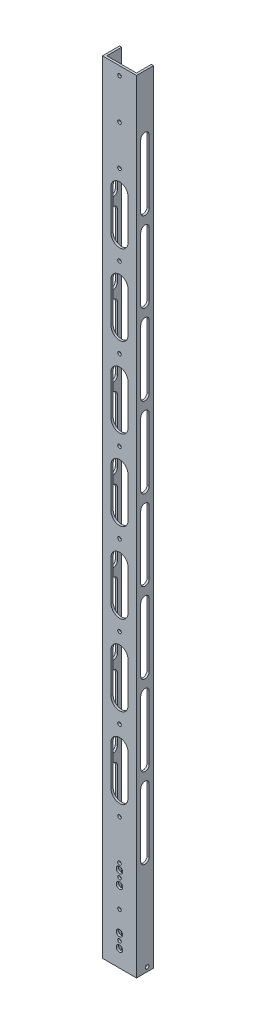
from build123d import *

# Parameters (mm, degrees)
BOSS_EXTRUDE1_DEPTH = 1168.4
IGUS_HOLES_REACH    = 27.4
SKETCH2_R           = 2.667
CUT_EXTRUDE2_REACH  = 5.175
SKETCH3_R           = 4.7625
SKETCH3_R_2         = 2.667
SKETCH4_R           = 2.667
CUT_EXTRUDE3_DEPTH  = 51.8
BACK_CUTS_REACH     = 27.4
CUT_EXTRUDE5_DEPTH  = 51.8


with BuildPart() as part:
    # Sketch1 → Boss-Extrude1 (new body)
    with BuildSketch(Plane(origin=(0, 0, 0), x_dir=(1, 0, 0), z_dir=(0, 1, 0))):
        Polygon((3.175, 3.175), (3.175, 25.4), (0, 25.4), (0, 0), (50.8, 0), (50.8, 25.4), (47.625, 25.4), (47.625, 3.175), align=None)
    extrude(amount=BOSS_EXTRUDE1_DEPTH)

    # Sketch2 → Igus_Holes (cut, up to next)
    with BuildSketch(Plane.XY, mode=Mode.PRIVATE) as igus_holes_sk1:
        with Locations((25.4, 76.2)):
            Circle(SKETCH2_R)
    igus_holes_tool1 = extrude(igus_holes_sk1.sketch, amount=-IGUS_HOLES_REACH, mode=Mode.PRIVATE) & part.part
    add(igus_holes_tool1.solids().sort_by_distance((25.4, 76.2, 0))[0], mode=Mode.SUBTRACT)
    # Sketch2 → Igus_Holes (cut, up to next)
    with BuildSketch(Plane.XY, mode=Mode.PRIVATE) as igus_holes_sk2:
        with Locations((25.4, 136.144)):
            Circle(SKETCH2_R)
    igus_holes_tool2 = extrude(igus_holes_sk2.sketch, amount=-IGUS_HOLES_REACH, mode=Mode.PRIVATE) & part.part
    add(igus_holes_tool2.solids().sort_by_distance((25.4, 136.144, 0))[0], mode=Mode.SUBTRACT)
    # Sketch2 → Igus_Holes (cut, up to next)
    with BuildSketch(Plane.XY, mode=Mode.PRIVATE) as igus_holes_sk3:
        with Locations((25.4, 196.088)):
            Circle(SKETCH2_R)
    igus_holes_tool3 = extrude(igus_holes_sk3.sketch, amount=-IGUS_HOLES_REACH, mode=Mode.PRIVATE) & part.part
    add(igus_holes_tool3.solids().sort_by_distance((25.4, 196.088, 0))[0], mode=Mode.SUBTRACT)
    # Sketch2 → Igus_Holes (cut, up to next)
    with BuildSketch(Plane.XY, mode=Mode.PRIVATE) as igus_holes_sk4:
        with Locations((25.4, 256.032)):
            Circle(SKETCH2_R)
    igus_holes_tool4 = extrude(igus_holes_sk4.sketch, amount=-IGUS_HOLES_REACH, mode=Mode.PRIVATE) & part.part
    add(igus_holes_tool4.solids().sort_by_distance((25.4, 256.032, 0))[0], mode=Mode.SUBTRACT)
    # Sketch2 → Igus_Holes (cut, up to next)
    with BuildSketch(Plane.XY, mode=Mode.PRIVATE) as igus_holes_sk5:
        with Locations((25.4, 315.976)):
            Circle(SKETCH2_R)
    igus_holes_tool5 = extrude(igus_holes_sk5.sketch, amount=-IGUS_HOLES_REACH, mode=Mode.PRIVATE) & part.part
    add(igus_holes_tool5.solids().sort_by_distance((25.4, 315.976, 0))[0], mode=Mode.SUBTRACT)
    # Sketch2 → Igus_Holes (cut, up to next)
    with BuildSketch(Plane.XY, mode=Mode.PRIVATE) as igus_holes_sk6:
        with Locations((25.4, 375.92)):
            Circle(SKETCH2_R)
    igus_holes_tool6 = extrude(igus_holes_sk6.sketch, amount=-IGUS_HOLES_REACH, mode=Mode.PRIVATE) & part.part
    add(igus_holes_tool6.solids().sort_by_distance((25.4, 375.92, 0))[0], mode=Mode.SUBTRACT)
    # Sketch2 → Igus_Holes (cut, up to next)
    with BuildSketch(Plane.XY, mode=Mode.PRIVATE) as igus_holes_sk7:
        with Locations((25.4, 435.864)):
            Circle(SKETCH2_R)
    igus_holes_tool7 = extrude(igus_holes_sk7.sketch, amount=-IGUS_HOLES_REACH, mode=Mode.PRIVATE) & part.part
    add(igus_holes_tool7.solids().sort_by_distance((25.4, 435.864, 0))[0], mode=Mode.SUBTRACT)
    # Sketch2 → Igus_Holes (cut, up to next)
    with BuildSketch(Plane.XY, mode=Mode.PRIVATE) as igus_holes_sk8:
        with Locations((25.4, 495.808)):
            Circle(SKETCH2_R)
    igus_holes_tool8 = extrude(igus_holes_sk8.sketch, amount=-IGUS_HOLES_REACH, mode=Mode.PRIVATE) & part.part
    add(igus_holes_tool8.solids().sort_by_distance((25.4, 495.808, 0))[0], mode=Mode.SUBTRACT)
    # Sketch2 → Igus_Holes (cut, up to next)
    with BuildSketch(Plane.XY, mode=Mode.PRIVATE) as igus_holes_sk9:
        with Locations((25.4, 555.752)):
            Circle(SKETCH2_R)
    igus_holes_tool9 = extrude(igus_holes_sk9.sketch, amount=-IGUS_HOLES_REACH, mode=Mode.PRIVATE) & part.part
    add(igus_holes_tool9.solids().sort_by_distance((25.4, 555.752, 0))[0], mode=Mode.SUBTRACT)
    # Sketch2 → Igus_Holes (cut, up to next)
    with BuildSketch(Plane.XY, mode=Mode.PRIVATE) as igus_holes_sk10:
        with Locations((25.4, 615.696)):
            Circle(SKETCH2_R)
    igus_holes_tool10 = extrude(igus_holes_sk10.sketch, amount=-IGUS_HOLES_REACH, mode=Mode.PRIVATE) & part.part
    add(igus_holes_tool10.solids().sort_by_distance((25.4, 615.696, 0))[0], mode=Mode.SUBTRACT)
    # Sketch2 → Igus_Holes (cut, up to next)
    with BuildSketch(Plane.XY, mode=Mode.PRIVATE) as igus_holes_sk11:
        with Locations((25.4, 675.64)):
            Circle(SKETCH2_R)
    igus_holes_tool11 = extrude(igus_holes_sk11.sketch, amount=-IGUS_HOLES_REACH, mode=Mode.PRIVATE) & part.part
    add(igus_holes_tool11.solids().sort_by_distance((25.4, 675.64, 0))[0], mode=Mode.SUBTRACT)
    # Sketch2 → Igus_Holes (cut, up to next)
    with BuildSketch(Plane.XY, mode=Mode.PRIVATE) as igus_holes_sk12:
        with Locations((25.4, 735.584)):
            Circle(SKETCH2_R)
    igus_holes_tool12 = extrude(igus_holes_sk12.sketch, amount=-IGUS_HOLES_REACH, mode=Mode.PRIVATE) & part.part
    add(igus_holes_tool12.solids().sort_by_distance((25.4, 735.584, 0))[0], mode=Mode.SUBTRACT)
    # Sketch2 → Igus_Holes (cut, up to next)
    with BuildSketch(Plane.XY, mode=Mode.PRIVATE) as igus_holes_sk13:
        with Locations((25.4, 795.528)):
            Circle(SKETCH2_R)
    igus_holes_tool13 = extrude(igus_holes_sk13.sketch, amount=-IGUS_HOLES_REACH, mode=Mode.PRIVATE) & part.part
    add(igus_holes_tool13.solids().sort_by_distance((25.4, 795.528, 0))[0], mode=Mode.SUBTRACT)
    # Sketch2 → Igus_Holes (cut, up to next)
    with BuildSketch(Plane.XY, mode=Mode.PRIVATE) as igus_holes_sk14:
        with Locations((25.4, 855.472)):
            Circle(SKETCH2_R)
    igus_holes_tool14 = extrude(igus_holes_sk14.sketch, amount=-IGUS_HOLES_REACH, mode=Mode.PRIVATE) & part.part
    add(igus_holes_tool14.solids().sort_by_distance((25.4, 855.472, 0))[0], mode=Mode.SUBTRACT)
    # Sketch2 → Igus_Holes (cut, up to next)
    with BuildSketch(Plane.XY, mode=Mode.PRIVATE) as igus_holes_sk15:
        with Locations((25.4, 915.416)):
            Circle(SKETCH2_R)
    igus_holes_tool15 = extrude(igus_holes_sk15.sketch, amount=-IGUS_HOLES_REACH, mode=Mode.PRIVATE) & part.part
    add(igus_holes_tool15.solids().sort_by_distance((25.4, 915.416, 0))[0], mode=Mode.SUBTRACT)
    # Sketch2 → Igus_Holes (cut, up to next)
    with BuildSketch(Plane.XY, mode=Mode.PRIVATE) as igus_holes_sk16:
        with Locations((25.4, 975.36)):
            Circle(SKETCH2_R)
    igus_holes_tool16 = extrude(igus_holes_sk16.sketch, amount=-IGUS_HOLES_REACH, mode=Mode.PRIVATE) & part.part
    add(igus_holes_tool16.solids().sort_by_distance((25.4, 975.36, 0))[0], mode=Mode.SUBTRACT)
    # Sketch2 → Igus_Holes (cut, up to next)
    with BuildSketch(Plane.XY, mode=Mode.PRIVATE) as igus_holes_sk17:
        with Locations((25.4, 1035.304)):
            Circle(SKETCH2_R)
    igus_holes_tool17 = extrude(igus_holes_sk17.sketch, amount=-IGUS_HOLES_REACH, mode=Mode.PRIVATE) & part.part
    add(igus_holes_tool17.solids().sort_by_distance((25.4, 1035.304, 0))[0], mode=Mode.SUBTRACT)
    # Sketch2 → Igus_Holes (cut, up to next)
    with BuildSketch(Plane.XY, mode=Mode.PRIVATE) as igus_holes_sk18:
        with Locations((25.4, 1095.248)):
            Circle(SKETCH2_R)
    igus_holes_tool18 = extrude(igus_holes_sk18.sketch, amount=-IGUS_HOLES_REACH, mode=Mode.PRIVATE) & part.part
    add(igus_holes_tool18.solids().sort_by_distance((25.4, 1095.248, 0))[0], mode=Mode.SUBTRACT)
    # Sketch2 → Igus_Holes (cut, up to next)
    with BuildSketch(Plane.XY, mode=Mode.PRIVATE) as igus_holes_sk19:
        with Locations((25.4, 1155.192)):
            Circle(SKETCH2_R)
    igus_holes_tool19 = extrude(igus_holes_sk19.sketch, amount=-IGUS_HOLES_REACH, mode=Mode.PRIVATE) & part.part
    add(igus_holes_tool19.solids().sort_by_distance((25.4, 1155.192, 0))[0], mode=Mode.SUBTRACT)

    # Sketch3 → Cut-Extrude2 (cut, up to next)
    with BuildSketch(Plane(origin=(0, 0, -3.175), x_dir=(-1, 0, 0), z_dir=(0, 0, -1)), mode=Mode.PRIVATE) as cut_extrude2_sk1:
        with Locations((-25.4, 25.4)):
            Circle(SKETCH3_R)
    cut_extrude2_tool1 = extrude(cut_extrude2_sk1.sketch, amount=-CUT_EXTRUDE2_REACH, mode=Mode.PRIVATE) & part.part
    add(cut_extrude2_tool1.solids().sort_by_distance((25.4, 25.4, -3.175))[0], mode=Mode.SUBTRACT)
    # Sketch3 → Cut-Extrude2 (cut, up to next)
    with BuildSketch(Plane(origin=(0, 0, -3.175), x_dir=(-1, 0, 0), z_dir=(0, 0, -1)), mode=Mode.PRIVATE) as cut_extrude2_sk2:
        with Locations((-25.400000019, 35.39998)):
            Circle(SKETCH3_R_2)
    cut_extrude2_tool2 = extrude(cut_extrude2_sk2.sketch, amount=-CUT_EXTRUDE2_REACH, mode=Mode.PRIVATE) & part.part
    add(cut_extrude2_tool2.solids().sort_by_distance((25.4, 35.39998, -3.175))[0], mode=Mode.SUBTRACT)
    # Sketch3 → Cut-Extrude2 (cut, up to next)
    with BuildSketch(Plane(origin=(0, 0, -3.175), x_dir=(-1, 0, 0), z_dir=(0, 0, -1)), mode=Mode.PRIVATE) as cut_extrude2_sk3:
        with Locations((-25.400000019, 117.00002)):
            Circle(SKETCH3_R_2)
    cut_extrude2_tool3 = extrude(cut_extrude2_sk3.sketch, amount=-CUT_EXTRUDE2_REACH, mode=Mode.PRIVATE) & part.part
    add(cut_extrude2_tool3.solids().sort_by_distance((25.4, 117.00002, -3.175))[0], mode=Mode.SUBTRACT)
    # Sketch3 → Cut-Extrude2 (cut, up to next)
    with BuildSketch(Plane(origin=(0, 0, -3.175), x_dir=(-1, 0, 0), z_dir=(0, 0, -1)), mode=Mode.PRIVATE) as cut_extrude2_sk4:
        with Locations((-25.400000019, 45.39996)):
            Circle(SKETCH3_R)
    cut_extrude2_tool4 = extrude(cut_extrude2_sk4.sketch, amount=-CUT_EXTRUDE2_REACH, mode=Mode.PRIVATE) & part.part
    add(cut_extrude2_tool4.solids().sort_by_distance((25.4, 45.39996, -3.175))[0], mode=Mode.SUBTRACT)
    # Sketch3 → Cut-Extrude2 (cut, up to next)
    with BuildSketch(Plane(origin=(0, 0, -3.175), x_dir=(-1, 0, 0), z_dir=(0, 0, -1)), mode=Mode.PRIVATE) as cut_extrude2_sk5:
        with Locations((-25.400000019, 107.00004)):
            Circle(SKETCH3_R)
    cut_extrude2_tool5 = extrude(cut_extrude2_sk5.sketch, amount=-CUT_EXTRUDE2_REACH, mode=Mode.PRIVATE) & part.part
    add(cut_extrude2_tool5.solids().sort_by_distance((25.4, 107.00004, -3.175))[0], mode=Mode.SUBTRACT)
    # Sketch3 → Cut-Extrude2 (cut, up to next)
    with BuildSketch(Plane(origin=(0, 0, -3.175), x_dir=(-1, 0, 0), z_dir=(0, 0, -1)), mode=Mode.PRIVATE) as cut_extrude2_sk6:
        with Locations((-25.400000019, 127)):
            Circle(SKETCH3_R)
    cut_extrude2_tool6 = extrude(cut_extrude2_sk6.sketch, amount=-CUT_EXTRUDE2_REACH, mode=Mode.PRIVATE) & part.part
    add(cut_extrude2_tool6.solids().sort_by_distance((25.4, 127, -3.175))[0], mode=Mode.SUBTRACT)

    # Sketch4 → Cut-Extrude3 (cut, through all)
    with BuildSketch(Plane.ZY):
        with Locations((-15.875, 6.35)):
            Circle(SKETCH4_R)
    extrude(amount=-CUT_EXTRUDE3_DEPTH, mode=Mode.SUBTRACT)

    # Sketch5 → Back_Cuts (cut, up to next)
    with BuildSketch(Plane.XY, mode=Mode.PRIVATE) as back_cuts_sk1:
        with BuildLine():
            Line((38.1, 1005.36), (38.1, 945.36))
            ThreePointArc((38.1, 945.36), (25.4, 932.66), (12.7, 945.36))
            Line((12.7, 945.36), (12.7, 1005.36))
            ThreePointArc((12.7, 1005.36), (25.4, 1018.06), (38.1, 1005.36))
        make_face()
    back_cuts_tool1 = extrude(back_cuts_sk1.sketch, amount=-BACK_CUTS_REACH, mode=Mode.PRIVATE) & part.part
    add(back_cuts_tool1.solids().sort_by_distance((25.4, 975.36, 0))[0], mode=Mode.SUBTRACT)
    # Sketch5 → Back_Cuts (cut, up to next)
    with BuildSketch(Plane.XY, mode=Mode.PRIVATE) as back_cuts_sk2:
        with BuildLine():
            Line((38.1, 885.472), (38.1, 825.472))
            ThreePointArc((38.1, 825.472), (25.4, 812.772), (12.7, 825.472))
            Line((12.7, 825.472), (12.7, 885.472))
            ThreePointArc((12.7, 885.472), (25.4, 898.172), (38.1, 885.472))
        make_face()
    back_cuts_tool2 = extrude(back_cuts_sk2.sketch, amount=-BACK_CUTS_REACH, mode=Mode.PRIVATE) & part.part
    add(back_cuts_tool2.solids().sort_by_distance((25.4, 855.472, 0))[0], mode=Mode.SUBTRACT)
    # Sketch5 → Back_Cuts (cut, up to next)
    with BuildSketch(Plane.XY, mode=Mode.PRIVATE) as back_cuts_sk3:
        with BuildLine():
            Line((38.1, 765.584), (38.1, 705.584))
            ThreePointArc((38.1, 705.584), (25.4, 692.884), (12.7, 705.584))
            Line((12.7, 705.584), (12.7, 765.584))
            ThreePointArc((12.7, 765.584), (25.4, 778.284), (38.1, 765.584))
        make_face()
    back_cuts_tool3 = extrude(back_cuts_sk3.sketch, amount=-BACK_CUTS_REACH, mode=Mode.PRIVATE) & part.part
    add(back_cuts_tool3.solids().sort_by_distance((25.4, 735.584, 0))[0], mode=Mode.SUBTRACT)
    # Sketch5 → Back_Cuts (cut, up to next)
    with BuildSketch(Plane.XY, mode=Mode.PRIVATE) as back_cuts_sk4:
        with BuildLine():
            Line((38.1, 645.696), (38.1, 585.696))
            ThreePointArc((38.1, 585.696), (25.4, 572.996), (12.7, 585.696))
            Line((12.7, 585.696), (12.7, 645.696))
            ThreePointArc((12.7, 645.696), (25.4, 658.396), (38.1, 645.696))
        make_face()
    back_cuts_tool4 = extrude(back_cuts_sk4.sketch, amount=-BACK_CUTS_REACH, mode=Mode.PRIVATE) & part.part
    add(back_cuts_tool4.solids().sort_by_distance((25.4, 615.696, 0))[0], mode=Mode.SUBTRACT)
    # Sketch5 → Back_Cuts (cut, up to next)
    with BuildSketch(Plane.XY, mode=Mode.PRIVATE) as back_cuts_sk5:
        with BuildLine():
            Line((38.1, 525.808), (38.1, 465.808))
            ThreePointArc((38.1, 465.808), (25.4, 453.108), (12.7, 465.808))
            Line((12.7, 465.808), (12.7, 525.808))
            ThreePointArc((12.7, 525.808), (25.4, 538.508), (38.1, 525.808))
        make_face()
    back_cuts_tool5 = extrude(back_cuts_sk5.sketch, amount=-BACK_CUTS_REACH, mode=Mode.PRIVATE) & part.part
    add(back_cuts_tool5.solids().sort_by_distance((25.4, 495.808, 0))[0], mode=Mode.SUBTRACT)
    # Sketch5 → Back_Cuts (cut, up to next)
    with BuildSketch(Plane.XY, mode=Mode.PRIVATE) as back_cuts_sk6:
        with BuildLine():
            Line((38.1, 405.92), (38.1, 345.92))
            ThreePointArc((38.1, 345.92), (25.4, 333.22), (12.7, 345.92))
            Line((12.7, 345.92), (12.7, 405.92))
            ThreePointArc((12.7, 405.92), (25.4, 418.62), (38.1, 405.92))
        make_face()
    back_cuts_tool6 = extrude(back_cuts_sk6.sketch, amount=-BACK_CUTS_REACH, mode=Mode.PRIVATE) & part.part
    add(back_cuts_tool6.solids().sort_by_distance((25.4, 375.92, 0))[0], mode=Mode.SUBTRACT)
    # Sketch5 → Back_Cuts (cut, up to next)
    with BuildSketch(Plane.XY, mode=Mode.PRIVATE) as back_cuts_sk7:
        with BuildLine():
            Line((38.1, 286.032), (38.1, 226.032))
            ThreePointArc((38.1, 226.032), (25.4, 213.332), (12.7, 226.032))
            Line((12.7, 226.032), (12.7, 286.032))
            ThreePointArc((12.7, 286.032), (25.4, 298.732), (38.1, 286.032))
        make_face()
    back_cuts_tool7 = extrude(back_cuts_sk7.sketch, amount=-BACK_CUTS_REACH, mode=Mode.PRIVATE) & part.part
    add(back_cuts_tool7.solids().sort_by_distance((25.4, 256.032, 0))[0], mode=Mode.SUBTRACT)

    # Sketch6 → Cut-Extrude5 (cut, through all)
    with BuildSketch(Plane.ZY):
        with BuildLine():
            Line((-6.35, 1082.05), (-6.35, 987.25))
            ThreePointArc((-6.35, 987.25), (-12.7, 980.9), (-19.05, 987.25))
            Line((-19.05, 987.25), (-19.05, 1082.05))
            ThreePointArc((-19.05, 1082.05), (-12.7, 1088.4), (-6.35, 1082.05))
        make_face()
        with BuildLine():
            Line((-6.35, 962.05), (-6.35, 867.25))
            ThreePointArc((-6.35, 867.25), (-12.7, 860.9), (-19.05, 867.25))
            Line((-19.05, 867.25), (-19.05, 962.05))
            ThreePointArc((-19.05, 962.05), (-12.7, 968.4), (-6.35, 962.05))
        make_face()
        with BuildLine():
            Line((-6.35, 842.05), (-6.35, 747.25))
            ThreePointArc((-6.35, 747.25), (-12.7, 740.9), (-19.05, 747.25))
            Line((-19.05, 747.25), (-19.05, 842.05))
            ThreePointArc((-19.05, 842.05), (-12.7, 848.4), (-6.35, 842.05))
        make_face()
        with BuildLine():
            Line((-6.35, 722.05), (-6.35, 627.25))
            ThreePointArc((-6.35, 627.25), (-12.7, 620.9), (-19.05, 627.25))
            Line((-19.05, 627.25), (-19.05, 722.05))
            ThreePointArc((-19.05, 722.05), (-12.7, 728.4), (-6.35, 722.05))
        make_face()
        with BuildLine():
            Line((-6.35, 602.05), (-6.35, 507.25))
            ThreePointArc((-6.35, 507.25), (-12.7, 500.9), (-19.05, 507.25))
            Line((-19.05, 507.25), (-19.05, 602.05))
            ThreePointArc((-19.05, 602.05), (-12.7, 608.4), (-6.35, 602.05))
        make_face()
        with BuildLine():
            Line((-6.35, 482.05), (-6.35, 387.25))
            ThreePointArc((-6.35, 387.25), (-12.7, 380.9), (-19.05, 387.25))
            Line((-19.05, 387.25), (-19.05, 482.05))
            ThreePointArc((-19.05, 482.05), (-12.7, 488.4), (-6.35, 482.05))
        make_face()
        with BuildLine():
            Line((-6.35, 362.05), (-6.35, 267.25))
            ThreePointArc((-6.35, 267.25), (-12.7, 260.9), (-19.05, 267.25))
            Line((-19.05, 267.25), (-19.05, 362.05))
            ThreePointArc((-19.05, 362.05), (-12.7, 368.4), (-6.35, 362.05))
        make_face()
        with BuildLine():
            Line((-6.35, 242.05), (-6.35, 147.25))
            ThreePointArc((-6.35, 147.25), (-12.7, 140.9), (-19.05, 147.25))
            Line((-19.05, 147.25), (-19.05, 242.05))
            ThreePointArc((-19.05, 242.05), (-12.7, 248.4), (-6.35, 242.05))
        make_face()
    extrude(amount=-CUT_EXTRUDE5_DEPTH, mode=Mode.SUBTRACT)


solid = part.part
